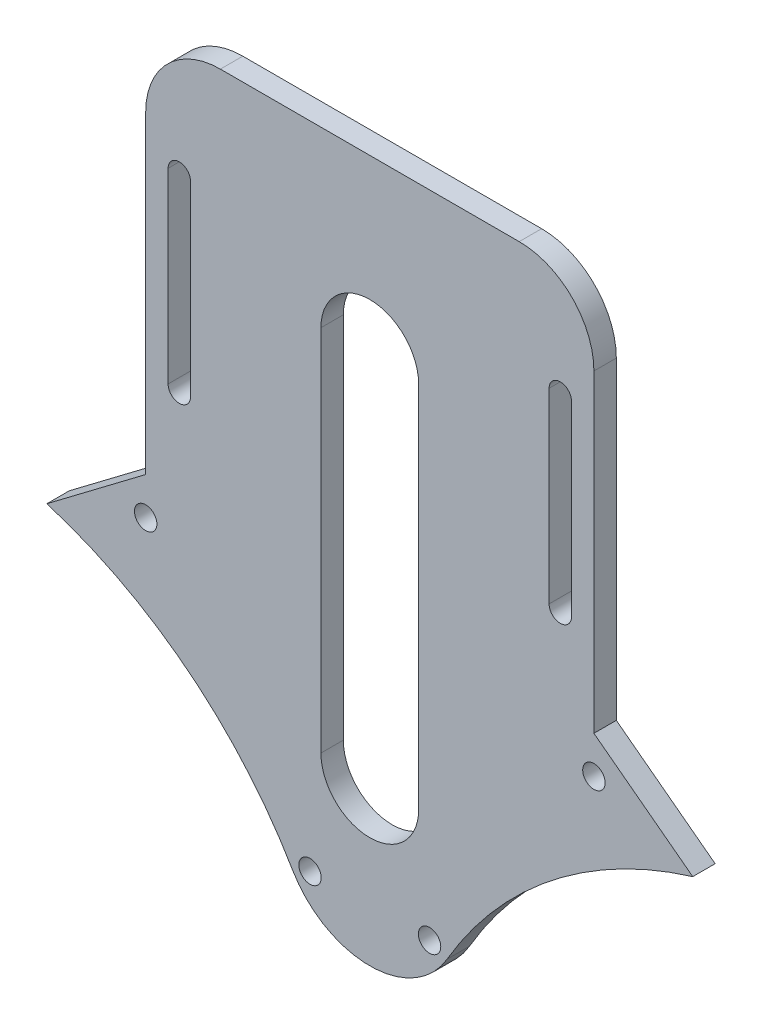
from build123d import *

# Parameters (mm, degrees)
SKETCH_1_R      = 1.5
EXTRUDE_1_DEPTH = 3


with BuildPart() as part:
    # 草图1 → 凸台-拉伸1 (new body)
    with BuildSketch(Plane.XY):
        with BuildLine():
            Line((30, 65), (43.229490169, 55))
            ThreePointArc((43.229490169, 55), (24.322951332, 45.093216766), (10.332713198, 28.972583968))
            ThreePointArc((10.332713198, 28.972583968), (0, 23.037780053), (-10.332713198, 28.972583968))
            ThreePointArc((-10.332713198, 28.972583968), (-24.322951332, 45.093216766), (-43.229490169, 55))
            Line((-43.229490169, 55), (-30, 65))
            Line((-30, 65), (-30, 107))
            ThreePointArc((-30, 107), (-27.071067812, 114.071067812), (-20, 117))
            Line((-20, 117), (20, 117))
            ThreePointArc((20, 117), (27.071067812, 114.071067812), (30, 107))
            Line((30, 107), (30, 65))
        make_face()
        with Locations((-30, 60)):
            Circle(SKETCH_1_R, mode=Mode.SUBTRACT)
        with Locations((-8, 30)):
            Circle(SKETCH_1_R, mode=Mode.SUBTRACT)
        with Locations((8, 30)):
            Circle(SKETCH_1_R, mode=Mode.SUBTRACT)
        with Locations((30, 60)):
            Circle(SKETCH_1_R, mode=Mode.SUBTRACT)
        with BuildLine():
            Line((27, 102), (27, 77))
            ThreePointArc((27, 77), (25.5, 75.5), (24, 77))
            Line((24, 77), (24, 102))
            ThreePointArc((24, 102), (25.5, 103.5), (27, 102))
        make_face(mode=Mode.SUBTRACT)
        with BuildLine():
            Line((-27, 102), (-27, 77))
            ThreePointArc((-27, 77), (-25.5, 75.5), (-24, 77))
            Line((-24, 77), (-24, 102))
            ThreePointArc((-24, 102), (-25.5, 103.5), (-27, 102))
        make_face(mode=Mode.SUBTRACT)
        with BuildLine():
            Line((-6.54179371, 44.438430627), (-6.54179371, 93.748949186))
            ThreePointArc((-6.54179371, 93.748949186), (0, 100.290742896), (6.54179371, 93.748949186))
            Line((6.54179371, 93.748949186), (6.54179371, 44.438430627))
            ThreePointArc((6.54179371, 44.438430627), (0, 37.896636917), (-6.54179371, 44.438430627))
        make_face(mode=Mode.SUBTRACT)
    extrude(amount=EXTRUDE_1_DEPTH)


solid = part.part
